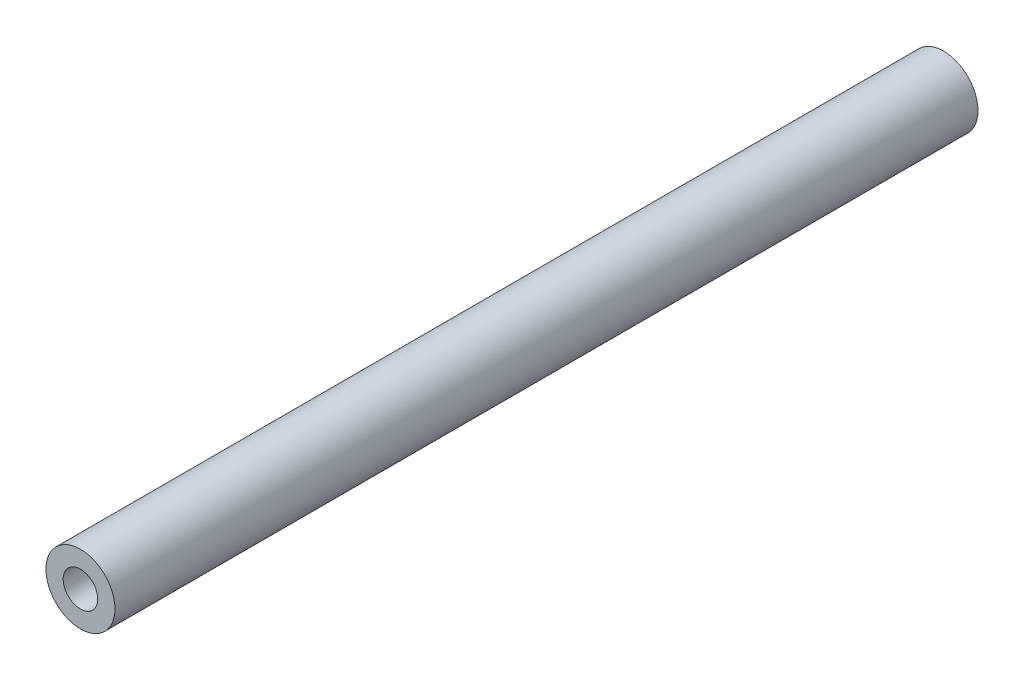
from build123d import *

# Parameters (mm, degrees)
SKETCH_1_R      = 4
SKETCH_1_R_2    = 2
EXTRUDE_1_DEPTH = 100


with BuildPart() as part:
    # 草图1 → 凸台-拉伸1 (new body)
    with BuildSketch(Plane.XY):
        with Locations((0, 2.653619029)):
            Circle(SKETCH_1_R)
        with Locations((0, 2.653619029)):
            Circle(SKETCH_1_R_2, mode=Mode.SUBTRACT)
    extrude(amount=EXTRUDE_1_DEPTH)


solid = part.part
